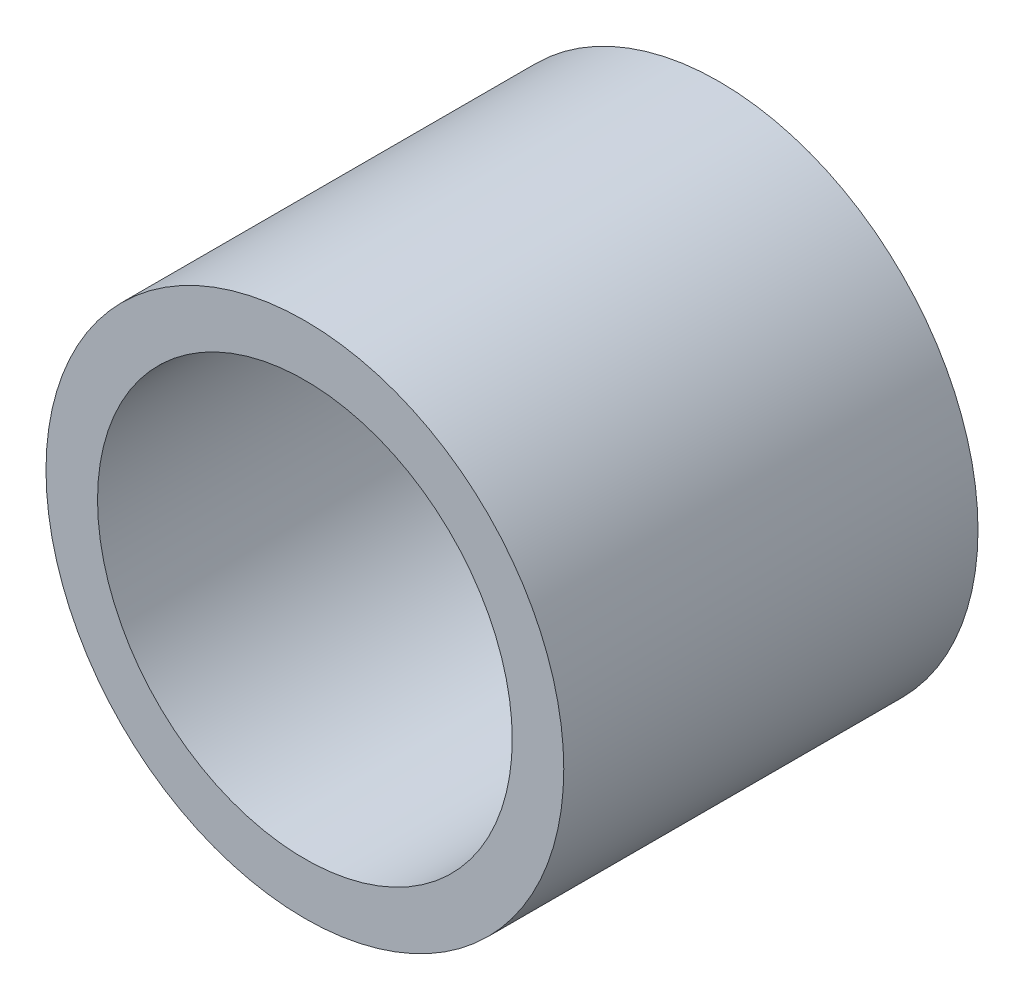
from build123d import *

# Parameters (mm, degrees)
SKETCH3_R                = 3.96875
SKETCH3_R_2              = 3.17881
BOSS_EXTRUDE1_DEPTH      = 3.175
BOSS_EXTRUDE1_DEPTH_BACK = 3.175


with BuildPart() as part:
    # Sketch3 → Boss-Extrude1 (new body, two sides)
    with BuildSketch(Plane.XY) as boss_extrude1_sk:
        Circle(SKETCH3_R)
        Circle(SKETCH3_R_2, mode=Mode.SUBTRACT)
    extrude(amount=BOSS_EXTRUDE1_DEPTH)
    extrude(boss_extrude1_sk.sketch, amount=-BOSS_EXTRUDE1_DEPTH_BACK)


solid = part.part
